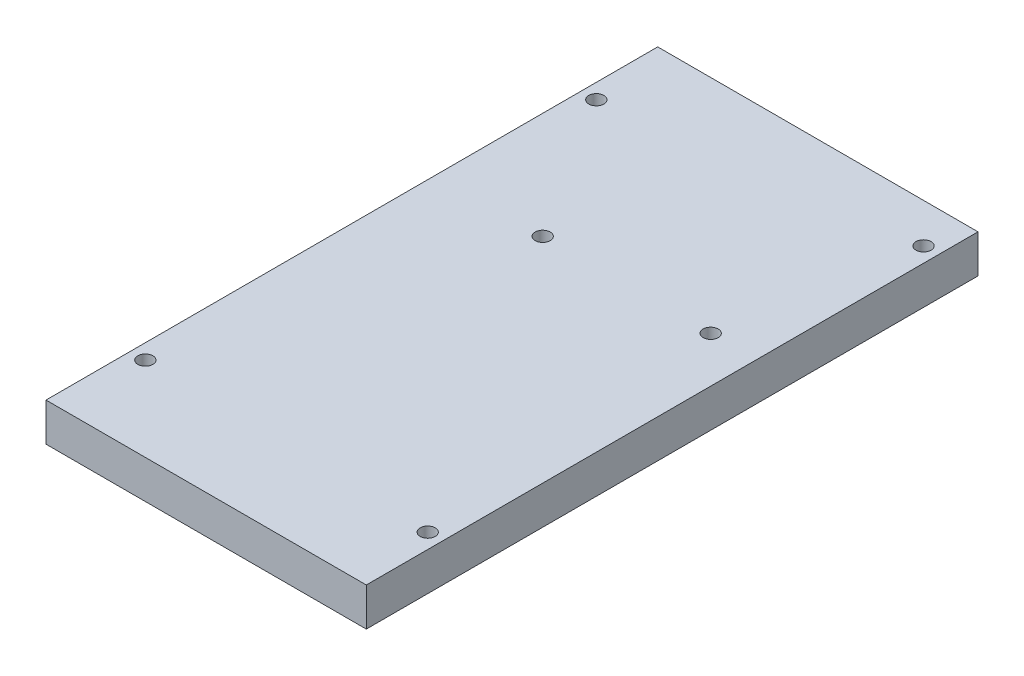
from build123d import *

# Parameters (mm, degrees)
SKETCH1_W           = 53.2
SKETCH1_H           = 101.6
SKETCH1_R           = 1.25
BOSS_EXTRUDE1_DEPTH = 6.35


with BuildPart() as part:
    # Sketch1 → Boss-Extrude1 (new body)
    with BuildSketch(Plane(origin=(0, 0, 0), x_dir=(1, 0, 0), z_dir=(0, 1, 0))):
        with Locations((-26.6, 50.8)):
            Rectangle(SKETCH1_W, SKETCH1_H)
        with Locations((-50.7, 88.9)):
            Circle(SKETCH1_R, mode=Mode.SUBTRACT)
        with Locations((-2.5, 95.05)):
            Circle(SKETCH1_R, mode=Mode.SUBTRACT)
        with Locations((-35.5, 64.8)):
            Circle(SKETCH1_R, mode=Mode.SUBTRACT)
        with Locations((-7.6, 64.8)):
            Circle(SKETCH1_R, mode=Mode.SUBTRACT)
        with Locations((-50.7, 14)):
            Circle(SKETCH1_R, mode=Mode.SUBTRACT)
        with Locations((-2.5, 12.7)):
            Circle(SKETCH1_R, mode=Mode.SUBTRACT)
    extrude(amount=BOSS_EXTRUDE1_DEPTH)


solid = part.part
